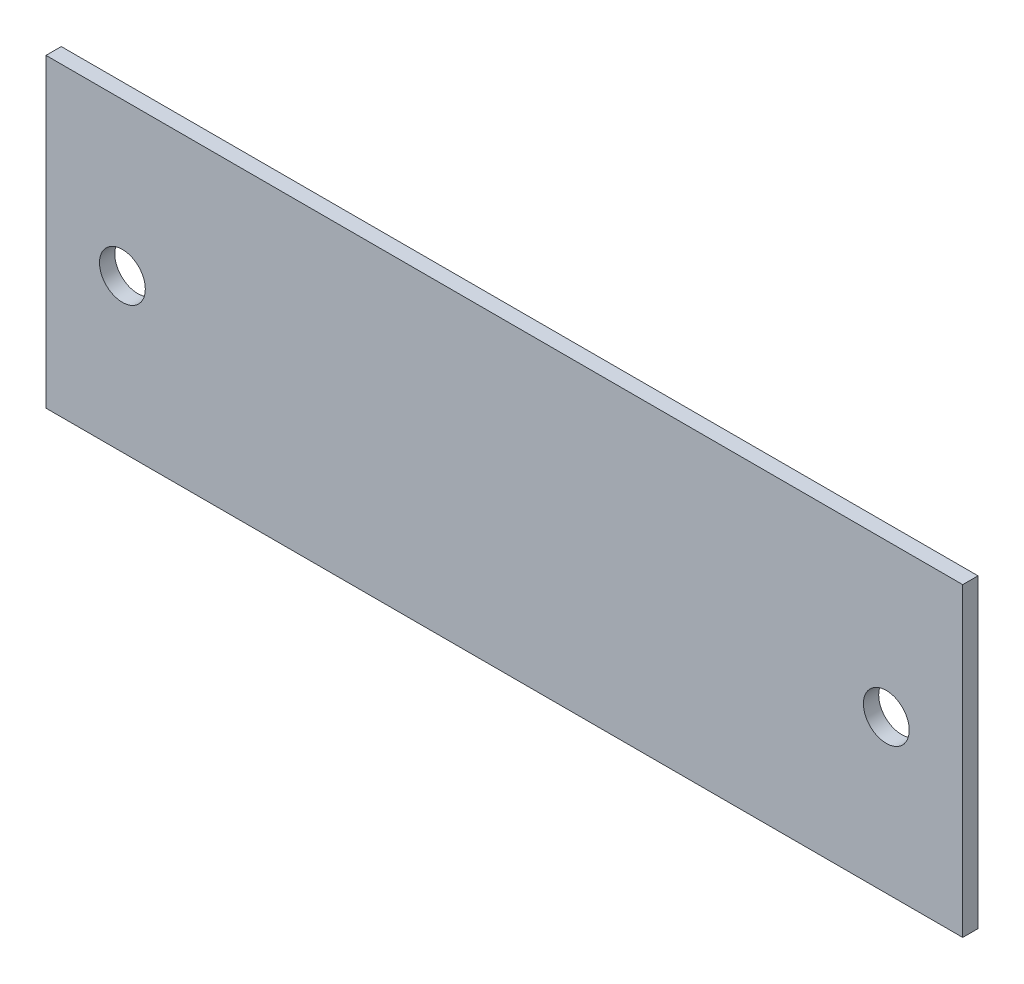
from build123d import *

# Parameters (mm, degrees)
ESBO_O1_W                = 60
ESBO_O1_H                = 20
RESSALTO_EXTRUS_O1_DEPTH = 1
ESBO_O2_R                = 1.5
CORTE_EXTRUS_O1_DEPTH    = 2


with BuildPart() as part:
    # Esboço1 → Ressalto-extrusão1 (new body)
    with BuildSketch(Plane.XY):
        with Locations((-42.624704013, -18.639795918)):
            Rectangle(ESBO_O1_W, ESBO_O1_H)
    extrude(amount=RESSALTO_EXTRUS_O1_DEPTH)

    # Esboço2 → Corte-extrusão1 (cut, through all)
    with BuildSketch(Plane.XY.offset(1)):
        with Locations((-67.624704013, -18.639795918)):
            Circle(ESBO_O2_R)
        with Locations(Location((-17.624704013, -18.639795918, 0), (0, 0, 180))):  # turned: the seam where the file's is
            Circle(ESBO_O2_R)
    extrude(amount=-CORTE_EXTRUS_O1_DEPTH, mode=Mode.SUBTRACT)


solid = part.part
